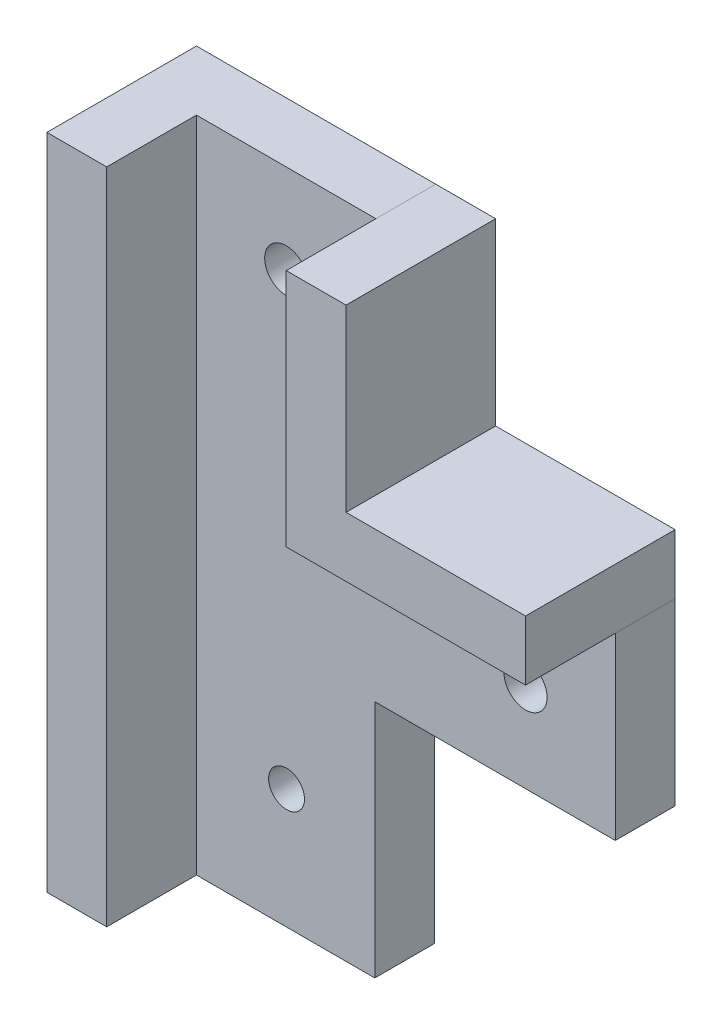
from build123d import *

# Parameters (mm, degrees)
BOSS_EXTRUDE1_DEPTH = 5
BOSS_EXTRUDE2_DEPTH = 12.5
BOSS_EXTRUDE3_DEPTH = 12.5
SKETCH4_R           = 1.8
CUT_EXTRUDE1_DEPTH  = 13.5
SKETCH6_W           = 14.9
SKETCH6_H           = 20
BOSS_EXTRUDE4_DEPTH = 5
SKETCH8_R           = 1.5
CUT_EXTRUDE2_DEPTH  = 6


with BuildPart() as part:
    # Sketch1 → Boss-Extrude1 (new body)
    with BuildSketch(Plane.XY):
        Polygon((7.370119522, -25.806772908), (27.470119522, -25.806772908), (27.470119522, -10.806772908), (7.470119522, -10.806772908), (7.470119522, 9.193227092), (-7.529880478, 9.193227092), (-7.529880478, -25.806772908), align=None)
    extrude(amount=BOSS_EXTRUDE1_DEPTH)

    # Sketch4 → Cut-Extrude1 (cut, through all)
    with BuildSketch(Plane(origin=(0, 0, 0), x_dir=(-1, 0, 0), z_dir=(0, 0, -1))):
        with Locations((0.029880478, 1.693227092)):
            Circle(SKETCH4_R)
        with Locations((-19.970119522, -18.306772908)):
            Circle(SKETCH4_R)
    extrude(amount=-CUT_EXTRUDE1_DEPTH, mode=Mode.SUBTRACT)



with BuildPart() as body_2:
    # Sketch2 → Boss-Extrude2 (new body)
    with BuildSketch(Plane(origin=(0, 0, 0), x_dir=(-1, 0, 0), z_dir=(0, 0, -1))):
        Polygon((-7.470119522, 9.193227092), (-12.470119522, 9.193227092), (-12.470119522, -5.806772908), (-27.470119522, -5.806772908), (-27.470119522, -10.806772908), (-7.470119522, -10.806772908), align=None)
    extrude(amount=-BOSS_EXTRUDE2_DEPTH)


with BuildPart() as body_3:
    # Sketch3 → Boss-Extrude3 (new body)
    with BuildSketch(Plane(origin=(0, 0, 0), x_dir=(-1, 0, 0), z_dir=(0, 0, -1))):
        Polygon((7.529880478, 9.193227092), (12.529880478, 9.193227092), (12.529880478, -45.806772908), (7.529880478, -45.806772908), (7.529880478, -25.806772908), align=None)
    extrude(amount=-BOSS_EXTRUDE3_DEPTH)


with BuildPart() as part_1:
    add(part.part)

    add(body_3.part)  # Boss-Extrude4 merges body 3
    # Sketch6 → Boss-Extrude4 (add)
    with BuildSketch(Plane.XY.offset(5)):
        with Locations((-0.079880478, -35.806772908)):
            Rectangle(SKETCH6_W, SKETCH6_H)
    extrude(amount=-BOSS_EXTRUDE4_DEPTH)

    # Sketch8 → Cut-Extrude2 (cut, through all)
    with BuildSketch(Plane.XY.offset(5)):
        with Locations((0, -35.806772908)):
            Circle(SKETCH8_R)
    extrude(amount=-CUT_EXTRUDE2_DEPTH, mode=Mode.SUBTRACT)


solid = Compound([body_2.part, part_1.part])
